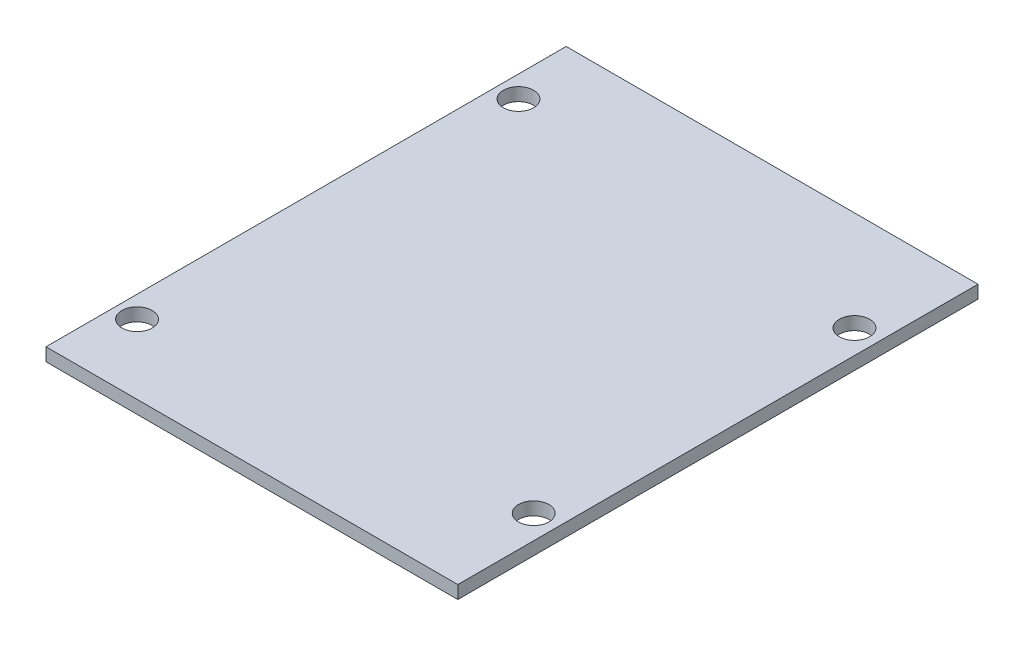
from build123d import *

# Parameters (mm, degrees)
SKETCH1_W           = 95
SKETCH1_H           = 120
BOSS_EXTRUDE1_DEPTH = 3
SKETCH2_R           = 3.5
CUT_EXTRUDE1_DEPTH  = 4


with BuildPart() as part:
    # Sketch1 → Boss-Extrude1 (new body)
    with BuildSketch(Plane(origin=(0, 0, 0), x_dir=(1, 0, 0), z_dir=(0, 1, 0))):
        with Locations((47.5, 60)):
            Rectangle(SKETCH1_W, SKETCH1_H)
    extrude(amount=BOSS_EXTRUDE1_DEPTH)

    # Sketch2 → Cut-Extrude1 (cut, through all)
    with BuildSketch(Plane(origin=(0, 3, 0), x_dir=(1, 0, 0), z_dir=(0, 1, 0))):
        with Locations((89.5, 23)):
            Circle(SKETCH2_R)
        with Locations((5, 16)):
            Circle(SKETCH2_R)
        with Locations((89.5, 97)):
            Circle(SKETCH2_R)
        with Locations((5, 104)):
            Circle(SKETCH2_R)
    extrude(amount=-CUT_EXTRUDE1_DEPTH, mode=Mode.SUBTRACT)


solid = part.part
